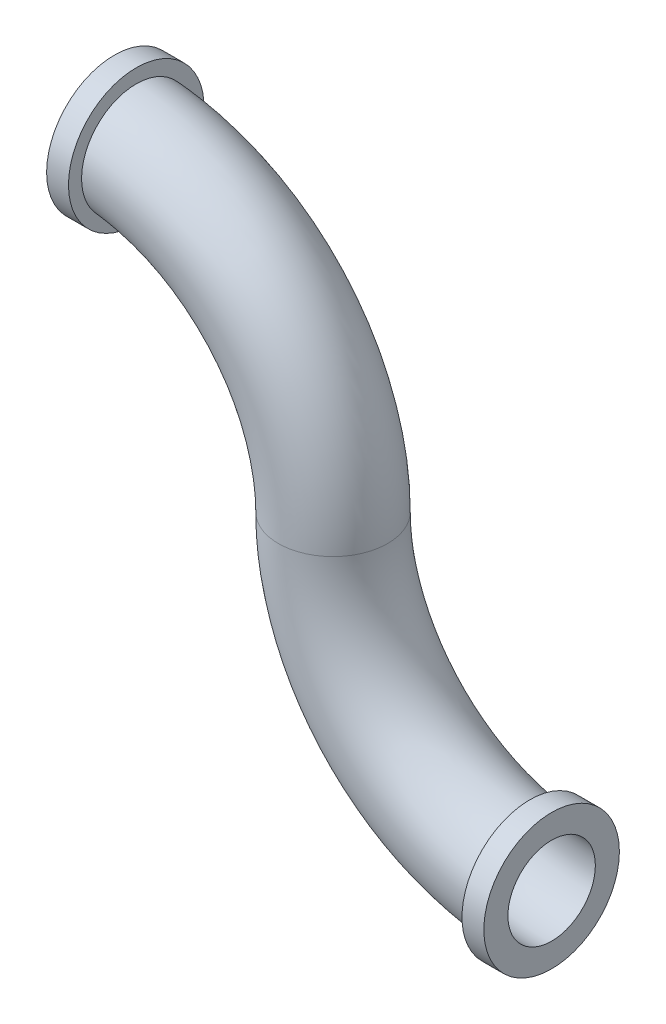
from build123d import *

# Parameters (mm, degrees)
IZIM3_R   = 0.25
IZIM3_R_2 = 0.2
IZIM8_R   = 0.31
IZIM8_R_2 = 0.21
IZIM9_R   = 0.31
IZIM9_R_2 = 0.21


with BuildPart() as part:
    # Süpür-İnce3: sweep along a path in Çizim1
    with BuildLine(Plane.XY) as s_p_r_nce3_path:
        ThreePointArc((1, -1), (0.292893219, -0.707106781), (0, 0))
        ThreePointArc((0, 0), (-0.292893219, 0.707106781), (-1, 1))
    # Çizim3 → Süpür-İnce3 (sweep)
    with BuildSketch(Plane(origin=(1, 0, 0), x_dir=(0, 0, -1), z_dir=(1, 0, 0))):
        with Locations((0, -1)):
            Circle(IZIM3_R)
        with Locations((0, -1)):
            Circle(IZIM3_R_2, mode=Mode.SUBTRACT)
    sweep(path=s_p_r_nce3_path.line)

    # Süpür-İnce5: sweep along a path in Çizim7
    with BuildLine(Plane.XY) as s_p_r_nce5_path:
        Line((-1, 1), (-0.9, 1))
    # Çizim8 → Süpür-İnce5 (sweep)
    with BuildSketch(Plane.ZY.offset(1)):
        with Locations((0, 1)):
            Circle(IZIM8_R)
        with Locations((0, 1)):
            Circle(IZIM8_R_2, mode=Mode.SUBTRACT)
    sweep(path=s_p_r_nce5_path.line)

    # Süpür-İnce6: sweep along a path in Çizim5
    with BuildLine(Plane.XY) as s_p_r_nce6_path:
        Line((1, -1), (0.9, -1))
    # Çizim9 → Süpür-İnce6 (sweep)
    with BuildSketch(Plane(origin=(1, 0, 0), x_dir=(0, 0, -1), z_dir=(1, 0, 0))):
        with Locations((0, -1)):
            Circle(IZIM9_R)
        with Locations((0, -1)):
            Circle(IZIM9_R_2, mode=Mode.SUBTRACT)
    sweep(path=s_p_r_nce6_path.line)


solid = part.part
